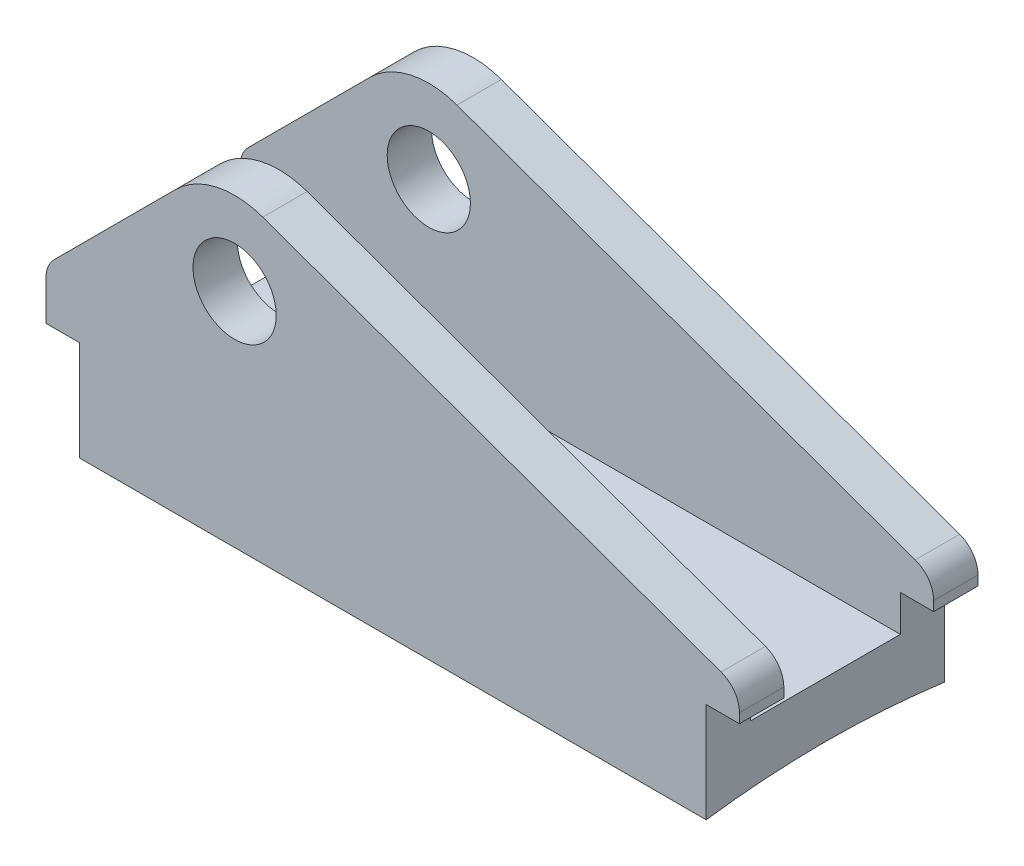
from build123d import *

# Parameters (mm, degrees)
BOSS_EXTRUDE2_DEPTH = 62.5
SKETCH4_R           = 7.5
SKETCH4_W           = 6
SKETCH4_H           = 18
CUT_EXTRUDE1_DEPTH  = 125
FILLET1_R           = 5


with BuildPart() as part:
    # Sketch3 → Boss-Extrude2 (new body, symmetric)
    with BuildSketch(Plane(origin=(0, 0, 0), x_dir=(0, 0, -1), z_dir=(1, 0, 0))):
        with BuildLine():
            Line((-21.5, 213.548888359), (-21.5, 158.548888359))
            ThreePointArc((-21.5, 158.548888359), (0, 160), (21.5, 158.548888359))
            Line((21.5, 158.548888359), (21.5, 213.548888359))
            Line((21.5, 213.548888359), (13.5, 213.548888359))
            Line((13.5, 213.548888359), (13.5, 170))
            Line((13.5, 170), (-13.5, 170))
            Line((-13.5, 170), (-13.5, 213.548888359))
            Line((-13.5, 213.548888359), (-21.5, 213.548888359))
        make_face()
    extrude(amount=BOSS_EXTRUDE2_DEPTH, both=True)

    # Sketch4 → Cut-Extrude1 (cut)
    with BuildSketch(Plane.XY.offset(21.5)):
        with BuildLine():
            Line((62.5, 213.548888359), (-28.5, 213.548888359))
            ThreePointArc((-28.5, 213.548888359), (-25.924800571, 213.326179989), (-23.426070272, 212.66466808))
            Line((-23.426070272, 212.66466808), (62.5, 181.778464764))
            Line((62.5, 181.778464764), (62.5, 213.548888359))
        make_face()
        with BuildLine():
            ThreePointArc((-62.5, 183.691023983), (-62.119397663, 185.604441145), (-61.035533906, 187.226557889))
            Line((-61.035533906, 187.226557889), (-39.106601718, 209.155490077))
            ThreePointArc((-39.106601718, 209.155490077), (-34.240251485, 212.407081347), (-28.5, 213.548888359))
            Line((-28.5, 213.548888359), (-62.5, 213.548888359))
            Line((-62.5, 213.548888359), (-62.5, 183.691023983))
        make_face()
        Polygon((-56.5, 176.548888359), (-62.5, 176.548888359), (-62.5, 173.092612301), (-62.5, 158.548888359), (-56.5, 158.548888359), align=None)
        with Locations((-28.5, 198.548888359)):
            Circle(SKETCH4_R)
        with Locations((59.5, 167.548888359)):
            Rectangle(SKETCH4_W, SKETCH4_H)
    extrude(amount=-CUT_EXTRUDE1_DEPTH, mode=Mode.SUBTRACT)

    # Fillet1
    fillet1_edges = [part.edges().sort_by_distance(p)[0] for p in [
        (62.5, 181.778464764, 17.5),
        (62.5, 181.778464764, -17.5),
    ]]
    fillet(fillet1_edges, radius=FILLET1_R)


solid = part.part
